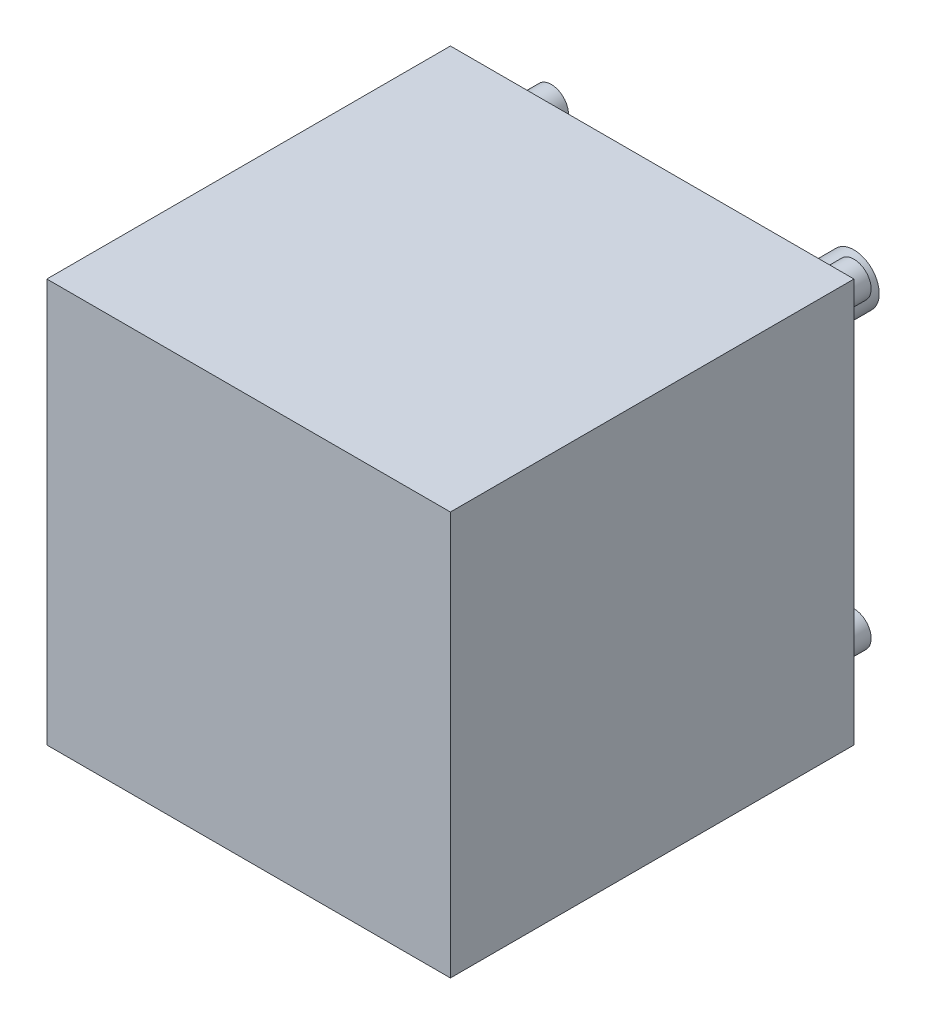
from build123d import *

# Parameters (mm, degrees)
SKETCH1_W               = 40
SKETCH1_H               = 40
BOSS_EXTRUDE1_DEPTH     = 40
SKETCH2_R               = 1.7
BOSS_EXTRUDE2_DEPTH     = 5
MIRROR2_COPY_1_SKETCH_R = 1.7
MIRROR2_COPY_1_DEPTH    = 5
SKETCH3_R               = 2.5
BOSS_EXTRUDE3_DEPTH     = 20


with BuildPart() as part:
    # Sketch1 → Boss-Extrude1 (new body)
    with BuildSketch(Plane.XY):
        Rectangle(SKETCH1_W, SKETCH1_H)
    extrude(amount=BOSS_EXTRUDE1_DEPTH)

    # Sketch2 → Boss-Extrude2 (add)
    with BuildSketch(Plane(origin=(0, 0, 0), x_dir=(-1, 0, 0), z_dir=(0, 0, -1))):
        with Locations((15, -15)):
            Circle(SKETCH2_R)
    boss_extrude2 = extrude(amount=BOSS_EXTRUDE2_DEPTH)

    # Mirror1: Boss-Extrude2 across plane
    add(boss_extrude2.mirror(Plane(origin=(0, 0, 0), x_dir=(0, 0, 1), z_dir=(1, 0, 0))))

    # Mirror2: Boss-Extrude2 across plane
    add(boss_extrude2.mirror(Plane.ZX))

    # Mirror2 copy 1 sketch → Mirror2 copy 1 (add)
    with BuildSketch(Plane(origin=(0, 0, 0), x_dir=(1, 0, 0), z_dir=(0, 0, -1))):
        with Locations((15, -15)):
            Circle(MIRROR2_COPY_1_SKETCH_R)
    extrude(amount=MIRROR2_COPY_1_DEPTH)

    # Sketch3 → Boss-Extrude3 (add)
    with BuildSketch(Plane(origin=(0, 0, 0), x_dir=(-1, 0, 0), z_dir=(0, 0, -1))):
        Circle(SKETCH3_R)
    extrude(amount=BOSS_EXTRUDE3_DEPTH)


solid = part.part
